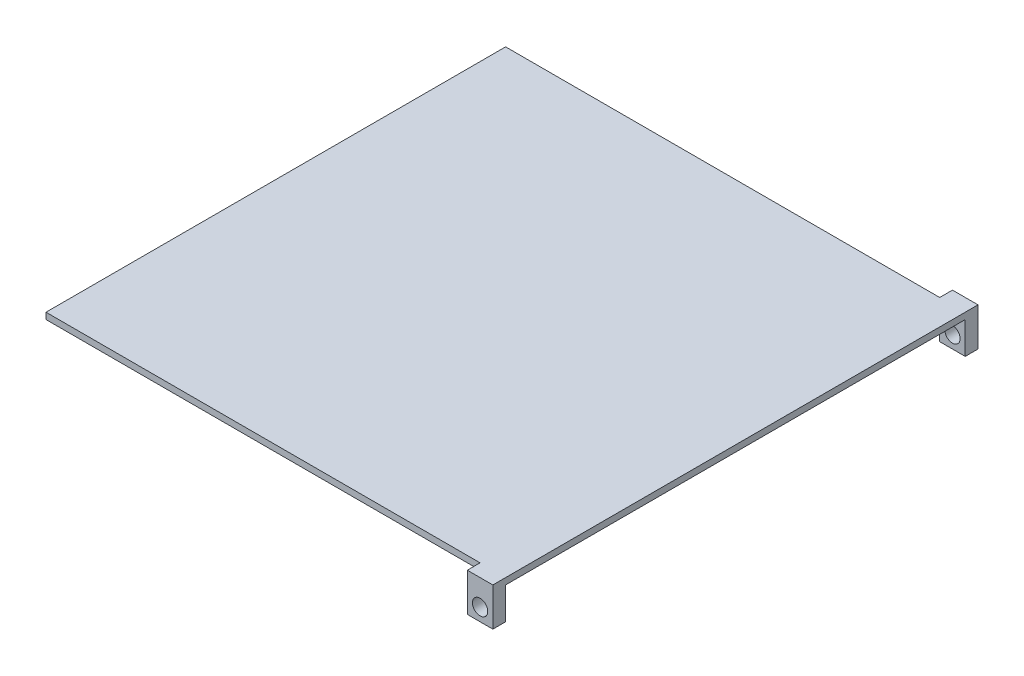
from build123d import *

# Parameters (mm, degrees)
SKETCH1_W           = 457.2
SKETCH1_H           = 228.6
BOSS_EXTRUDE1_DEPTH = 6.35
SKETCH2_W           = 25.4
SKETCH2_H           = 38.1
SKETCH2_R           = 7.62
BOSS_EXTRUDE2_DEPTH = 12.7
SKETCH4_R           = 3.175
BOSS_EXTRUDE4_DEPTH = 7.62


with BuildPart() as part:
    # Sketch1 → Boss-Extrude1 (new body)
    with BuildSketch(Plane(origin=(0, 0, 0), x_dir=(1, 0, 0), z_dir=(0, 1, 0))):
        with Locations((228.6, 114.3)):
            Rectangle(SKETCH1_W, SKETCH1_H)
    boss_extrude1 = extrude(amount=BOSS_EXTRUDE1_DEPTH)

    # Sketch2 → Boss-Extrude2 (add)
    with BuildSketch(Plane.XY):
        with Locations((444.5, -12.7)):
            Rectangle(SKETCH2_W, SKETCH2_H)
        with Locations((444.5, -19.05)):
            Circle(SKETCH2_R, mode=Mode.SUBTRACT)
    boss_extrude2 = extrude(amount=BOSS_EXTRUDE2_DEPTH)

    # Mirror3: Boss-Extrude1, Boss-Extrude2 across plane
    add(boss_extrude1.mirror(Plane(origin=(0, 6.35, -228.6), x_dir=(1, 0, 0), z_dir=(0, 0, 1))))
    add(boss_extrude2.mirror(Plane(origin=(0, 6.35, -228.6), x_dir=(1, 0, 0), z_dir=(0, 0, 1))))

    # Sketch4 → Boss-Extrude4 (add)
    with BuildSketch(Plane.XZ):
        with Locations((228.6, -228.6)):
            Circle(SKETCH4_R)
    extrude(amount=BOSS_EXTRUDE4_DEPTH)


solid = part.part
